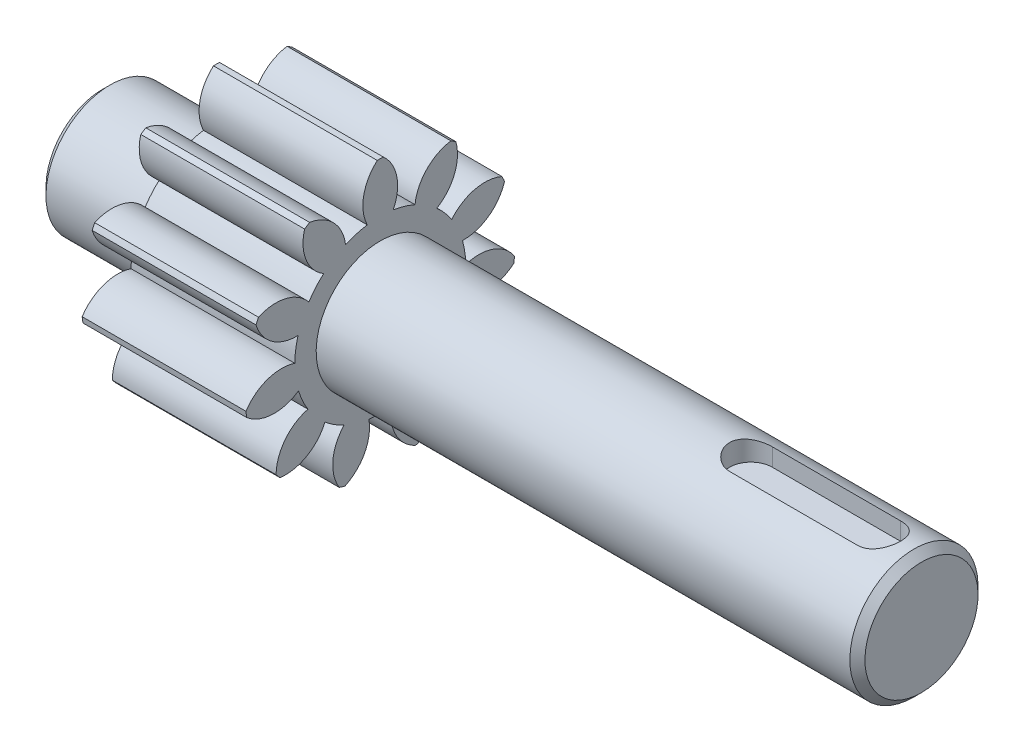
from build123d import *

# Parameters (mm, degrees)
BOSS_EXTRUDE1_DEPTH = 23
CUT_EXTRUDE1_DEPTH  = 3


with BuildPart() as part:
    # Sketch1 → Revolve1 (revolve)
    with BuildSketch(Plane.XY):
        Polygon((-57.5, 0), (-57.5, -7.939339828), (-56.439339828, -9), (56.439339828, -9), (57.5, -7.939339828), (57.5, 0), align=None)
    revolve(axis=Axis((-100, 0, 0), (1, 0, 0)))

    # Sketch2 → Boss-Extrude1 (add)
    with BuildSketch(Plane.ZY.offset(41.5)):
        with BuildLine():
            ThreePointArc((-7.947510586, 8.990944082), (-10.426372404, 11.920385617), (-10.622991997, 15.752842316))
            ThreePointArc((-10.622991997, 15.752842316), (-10.272175532, 15.983817124), (-9.91633903, 16.206980602))
            ThreePointArc((-9.91633903, 16.206980602), (-6.511892526, 14.43606908), (-4.876935192, 10.964283065))
            ThreePointArc((-4.876935192, 10.964283065), (-3.380790682, 11.513915683), (-1.825, 11.860412092))
            ThreePointArc((-1.825, 11.860412092), (-2.326575595, 15.664989012), (-0.42, 18.995357328))
            ThreePointArc((-0.42, 18.995357328), (0, 19), (0.42, 18.995357328))
            ThreePointArc((0.42, 18.995357328), (2.326575595, 15.664989012), (1.825, 11.860412092))
            ThreePointArc((1.825, 11.860412092), (3.380790682, 11.513915683), (4.876935192, 10.964283065))
            ThreePointArc((4.876935192, 10.964283065), (6.511892526, 14.43606908), (9.91633903, 16.206980602))
            ThreePointArc((9.91633903, 16.206980602), (10.272175532, 15.983817124), (10.622991997, 15.752842316))
            ThreePointArc((10.622991997, 15.752842316), (10.426372404, 11.920385617), (7.947510586, 8.990944082))
            ThreePointArc((7.947510586, 8.990944082), (9.068994892, 7.858328807), (10.030477919, 6.587071635))
            ThreePointArc((10.030477919, 6.587071635), (13.282880781, 8.623799215), (17.104310483, 8.273002049))
            ThreePointArc((17.104310483, 8.273002049), (17.283007912, 7.892885247), (17.453259094, 7.508911173))
            ThreePointArc((17.453259094, 7.508911173), (15.215869643, 4.391144013), (11.546742716, 3.266914852))
            ThreePointArc((11.546742716, 3.266914852), (11.877857303, 1.707778059), (11.999414778, 0.118511503))
            ThreePointArc((11.999414778, 0.118511503), (15.836648241, 0.073534032), (18.861784211, -2.2875962))
            ThreePointArc((18.861784211, -2.2875962), (18.806607396, -2.703981927), (18.742239747, -3.119046212))
            ThreePointArc((18.742239747, -3.119046212), (15.174435781, -4.532254788), (11.479965619, -3.49433676))
            ThreePointArc((11.479965619, -3.49433676), (10.915583944, -4.984980156), (10.15862223, -6.387675194))
            ThreePointArc((10.15862223, -6.387675194), (13.36239178, -8.500077686), (14.630774723, -12.12189882))
            ThreePointArc((14.630774723, -12.12189882), (14.359241913, -12.442353945), (14.080691707, -12.756728462))
            ThreePointArc((14.080691707, -12.756728462), (10.315225776, -12.016694717), (7.768380551, -9.146161141))
            ThreePointArc((7.768380551, -9.146161141), (6.487689809, -10.095042394), (5.092538901, -10.865820151))
            ThreePointArc((5.092538901, -10.865820151), (6.645670343, -14.374974798), (5.754597637, -18.107584213))
            ThreePointArc((5.754597637, -18.107584213), (5.35291858, -18.230366499), (4.948623539, -18.344239561))
            ThreePointArc((4.948623539, -18.344239561), (2.181004471, -15.68591898), (1.590389547, -11.894143983))
            ThreePointArc((1.590389547, -11.894143983), (0, -12), (-1.590389547, -11.894143983))
            ThreePointArc((-1.590389547, -11.894143983), (-2.181004471, -15.68591898), (-4.948623539, -18.344239561))
            ThreePointArc((-4.948623539, -18.344239561), (-5.35291858, -18.230366499), (-5.754597637, -18.107584213))
            ThreePointArc((-5.754597637, -18.107584213), (-6.645670343, -14.374974798), (-5.092538901, -10.865820151))
            ThreePointArc((-5.092538901, -10.865820151), (-6.487689809, -10.095042394), (-7.768380551, -9.146161141))
            ThreePointArc((-7.768380551, -9.146161141), (-10.315225776, -12.016694717), (-14.080691707, -12.756728462))
            ThreePointArc((-14.080691707, -12.756728462), (-14.359241913, -12.442353945), (-14.630774723, -12.12189882))
            ThreePointArc((-14.630774723, -12.12189882), (-13.36239178, -8.500077686), (-10.15862223, -6.387675194))
            ThreePointArc((-10.15862223, -6.387675194), (-10.915583944, -4.984980156), (-11.479965619, -3.49433676))
            ThreePointArc((-11.479965619, -3.49433676), (-15.174435781, -4.532254788), (-18.742239747, -3.119046212))
            ThreePointArc((-18.742239747, -3.119046212), (-18.806607396, -2.703981927), (-18.861784211, -2.2875962))
            ThreePointArc((-18.861784211, -2.2875962), (-15.836648241, 0.073534032), (-11.999414778, 0.118511503))
            ThreePointArc((-11.999414778, 0.118511503), (-11.877857303, 1.707778059), (-11.546742716, 3.266914852))
            ThreePointArc((-11.546742716, 3.266914852), (-15.215869643, 4.391144013), (-17.453259094, 7.508911173))
            ThreePointArc((-17.453259094, 7.508911173), (-17.283007912, 7.892885247), (-17.104310483, 8.273002049))
            ThreePointArc((-17.104310483, 8.273002049), (-13.282880781, 8.623799215), (-10.030477919, 6.587071635))
            ThreePointArc((-10.030477919, 6.587071635), (-9.068994892, 7.858328807), (-7.947510586, 8.990944082))
        make_face()
    extrude(amount=-BOSS_EXTRUDE1_DEPTH)

    # Sketch4 → Cut-Extrude1 (cut)
    with BuildSketch(Plane(origin=(0, 9, 0), x_dir=(1, 0, 0), z_dir=(0, 1, 0))):
        with BuildLine():
            Line((33.550041919, 3), (51.550041919, 3))
            ThreePointArc((51.550041919, 3), (54.550041919, 0), (51.550041919, -3))
            Line((51.550041919, -3), (33.550041919, -3))
            ThreePointArc((33.550041919, -3), (30.550041919, 0), (33.550041919, 3))
        make_face()
    extrude(amount=-CUT_EXTRUDE1_DEPTH, mode=Mode.SUBTRACT)


solid = part.part
